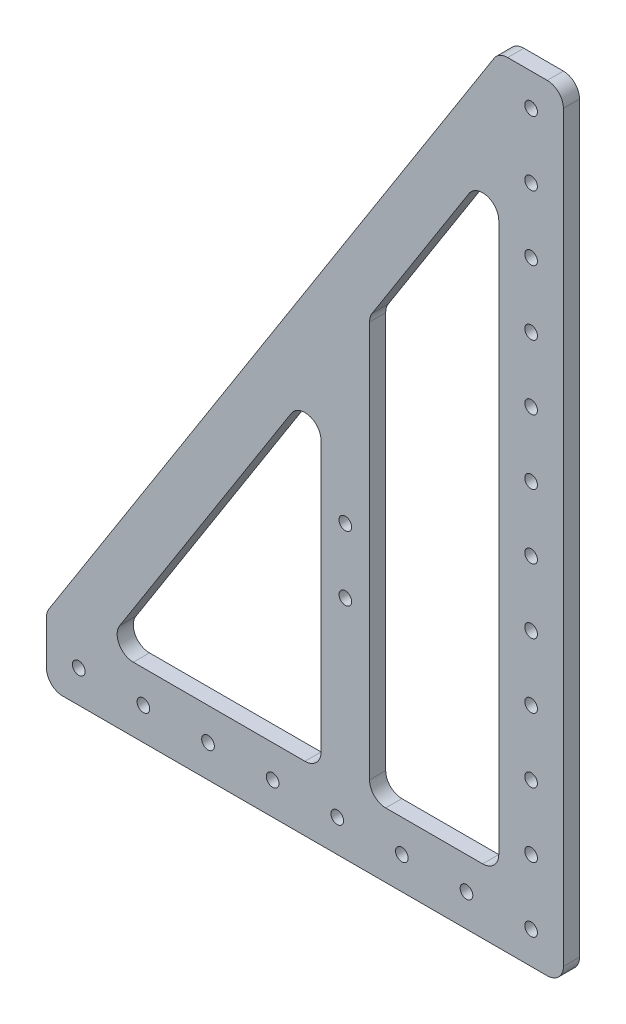
from build123d import *

# Parameters (mm, degrees)
BOSS_EXTRUDE1_DEPTH = 6.35
SKETCH2_R           = 2.4892
CUT_EXTRUDE1_DEPTH  = 7.35
SKETCH4_R           = 2.4892
BOSS_EXTRUDE2_DEPTH = 6.35
FILLET1_R           = 6.35


with BuildPart() as part:
    # Sketch1 → Boss-Extrude1 (new body)
    with BuildSketch(Plane.XY):
        Polygon((0, 25.4), (177.8, 304.8), (203.2, 304.8), (203.2, 0), (0, 0), align=None)
    extrude(amount=BOSS_EXTRUDE1_DEPTH)

    # Sketch2 → Cut-Extrude1 (cut, through all)
    with BuildSketch(Plane.XY.offset(6.35)):
        with Locations((190.5, 12.7)):
            Circle(SKETCH2_R)
        with Locations((165.1, 12.7)):
            Circle(SKETCH2_R)
        with Locations((139.7, 12.7)):
            Circle(SKETCH2_R)
        with Locations((114.3, 12.7)):
            Circle(SKETCH2_R)
        with Locations((88.9, 12.7)):
            Circle(SKETCH2_R)
        with Locations((63.5, 12.7)):
            Circle(SKETCH2_R)
        with Locations((38.1, 12.7)):
            Circle(SKETCH2_R)
        with Locations((190.5, 38.1)):
            Circle(SKETCH2_R)
        with Locations((190.5, 63.5)):
            Circle(SKETCH2_R)
        with Locations((190.5, 88.9)):
            Circle(SKETCH2_R)
        with Locations((190.5, 114.3)):
            Circle(SKETCH2_R)
        with Locations((190.5, 139.7)):
            Circle(SKETCH2_R)
        with Locations((190.5, 165.1)):
            Circle(SKETCH2_R)
        with Locations((190.5, 190.5)):
            Circle(SKETCH2_R)
        with Locations((190.5, 215.9)):
            Circle(SKETCH2_R)
        with Locations((190.5, 241.3)):
            Circle(SKETCH2_R)
        with Locations((190.5, 266.7)):
            Circle(SKETCH2_R)
        with Locations((190.5, 292.1)):
            Circle(SKETCH2_R)
        with Locations((12.7, 12.7)):
            Circle(SKETCH2_R)
        Polygon((22.580146513, 25.4), (177.8, 25.4), (177.8, 269.316912623), align=None)
    extrude(amount=-CUT_EXTRUDE1_DEPTH, mode=Mode.SUBTRACT)

    # Sketch4 → Boss-Extrude2 (add)
    with BuildSketch(Plane(origin=(0, 0, 0), x_dir=(-1, 0, 0), z_dir=(0, 0, -1))):
        Polygon((-107.95, 25.4), (-107.95, 159.552626909), (-127, 189.488341195), (-127, 25.4), align=None)
        with Locations((-117.475, 88.9)):
            Circle(SKETCH4_R, mode=Mode.SUBTRACT)
        with Locations((-117.475, 114.3)):
            Circle(SKETCH4_R, mode=Mode.SUBTRACT)
    extrude(amount=-BOSS_EXTRUDE2_DEPTH)

    # Fillet1
    fillet1_edges = [part.edges().sort_by_distance(p)[0] for p in [
        (127, 25.4, 3.175),
        (127, 189.488341195, 3.175),
        (107.95, 159.552626909, 3.175),
        (107.95, 25.4, 3.175),
        (22.580146513, 25.4, 3.175),
        (177.8, 269.316912623, 3.175),
        (177.8, 25.4, 3.175),
        (203.2, 0, 3.175),
        (0, 0, 3.175),
        (0, 25.4, 3.175),
        (177.8, 304.8, 3.175),
        (203.2, 304.8, 3.175),
    ]]
    fillet(fillet1_edges, radius=FILLET1_R)


solid = part.part
